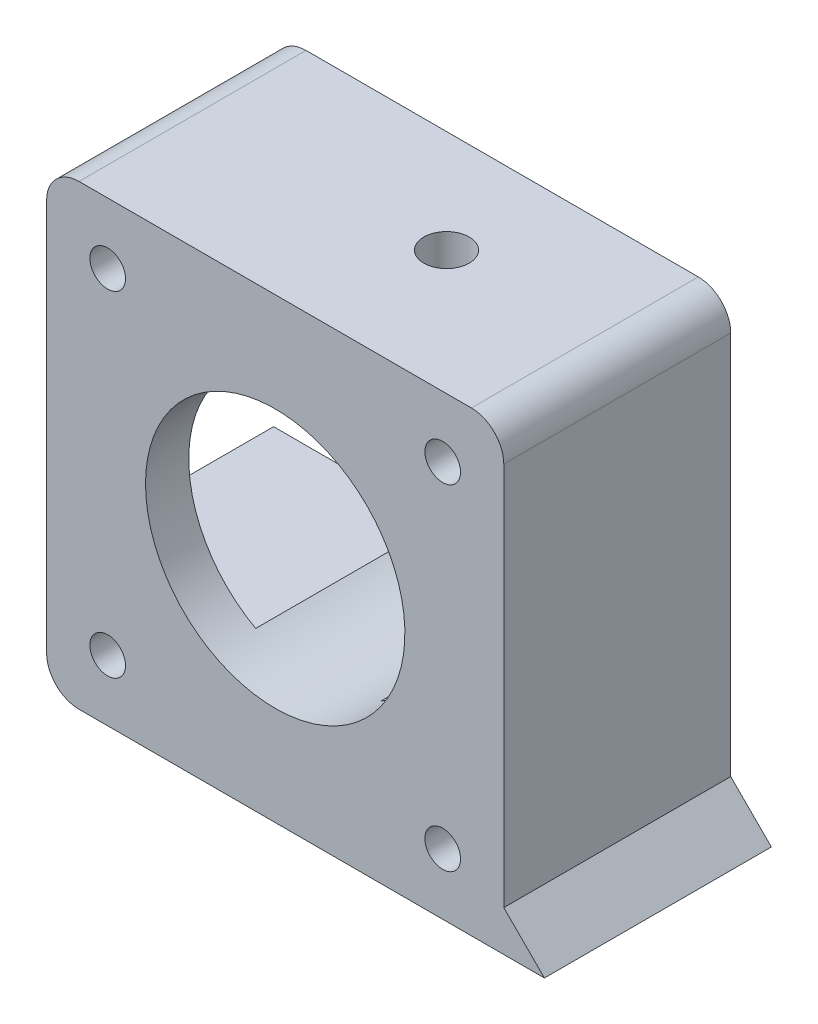
from build123d import *

# Parameters (mm, degrees)
IZIM1_R                     = 1.65
Y_KSEKLIK_EKSTR_ZYON1_DEPTH = 21
RADYUS1_R                   = 3
IZIM4_W                     = 17
IZIM4_H                     = 21
KES_EKSTR_ZYON3_DEPTH       = 40
IZIM5_R                     = 2.1
KES_EKSTR_ZYON4_DEPTH       = 55
IZIM2_R                     = 12
KES_EKSTR_ZYON1_DEPTH       = 10
KES_EKSTR_ZYON1_DEPTH_BACK  = 23
KES_EKSTR_ZYON5_DEPTH       = 15


with BuildPart() as part:
    # Çizim1 → Yükseklik-Ekstrüzyon1 (new body)
    with BuildSketch(Plane.XY):
        Polygon((-6.954216705, -22.021401373), (-4.12578958, -22.021401373), (7.545783295, -22.021401373), (10.37421042, -22.021401373), (18.259996857, -22.021401373), (22.019996857, -22.021401373), (18.259996857, -18.261401373), (18.259996857, 20.278598627), (-24.040003143, 20.278598627), (-24.040003143, -22.021401373), align=None)
        with Locations((-18.390003143, 14.628598627)):
            Circle(IZIM1_R, mode=Mode.SUBTRACT)
        with Locations((12.609996857, 14.628598627)):
            Circle(IZIM1_R, mode=Mode.SUBTRACT)
        with Locations((-18.390003143, -16.371401373)):
            Circle(IZIM1_R, mode=Mode.SUBTRACT)
        with Locations((12.609996857, -16.371401373)):
            Circle(IZIM1_R, mode=Mode.SUBTRACT)
    extrude(amount=Y_KSEKLIK_EKSTR_ZYON1_DEPTH)

    # Radyus1
    radyus1_edges = [part.edges().sort_by_distance(p)[0] for p in [
        (-24.040003143, 20.278598627, 10.5),
        (18.259996857, 20.278598627, 10.5),
        (-24.040003143, -22.021401373, 10.5),
    ]]
    fillet(radyus1_edges, radius=RADYUS1_R)

    # Çizim4 → Kes-Ekstrüzyon3 (cut)
    with BuildSketch(Plane.ZY.offset(24.040003143)):
        with Locations((8.5, -0.871401373)):
            Rectangle(IZIM4_W, IZIM4_H)
    extrude(amount=-KES_EKSTR_ZYON3_DEPTH, mode=Mode.SUBTRACT)

    # Çizim5 → Kes-Ekstrüzyon4 (cut)
    with BuildSketch(Plane(origin=(0, 20.278598627, 0), x_dir=(1, 0, 0), z_dir=(0, 1, 0))):
        with Locations((1.459996857, -9.5)):
            Circle(IZIM5_R)
    extrude(amount=-KES_EKSTR_ZYON4_DEPTH, mode=Mode.SUBTRACT)

    # Çizim2 → Kes-Ekstrüzyon1 (cut, two sides)
    with BuildSketch(Plane(origin=(0, 0, 0), x_dir=(-1, 0, 0), z_dir=(0, 0, -1))) as kes_ekstr_zyon1_sk:
        with Locations((2.890003143, -0.871401373)):
            Circle(IZIM2_R)
    extrude(amount=KES_EKSTR_ZYON1_DEPTH, mode=Mode.SUBTRACT)
    extrude(kes_ekstr_zyon1_sk.sketch, amount=-KES_EKSTR_ZYON1_DEPTH_BACK, mode=Mode.SUBTRACT)

    # Çizim6 → Kes-Ekstrüzyon5 (cut)
    with BuildSketch(Plane.XZ.offset(22.021401373)):
        with BuildLine():
            Line((-0.640003143, 9.5), (-0.640003143, 0))
            Line((-0.640003143, 0), (3.559996857, 0))
            Line((3.559996857, 0), (3.559996857, 9.5))
            ThreePointArc((3.559996857, 9.5), (1.459996857, 11.6), (-0.640003143, 9.5))
        make_face()
    extrude(amount=-KES_EKSTR_ZYON5_DEPTH, mode=Mode.SUBTRACT)


solid = part.part
